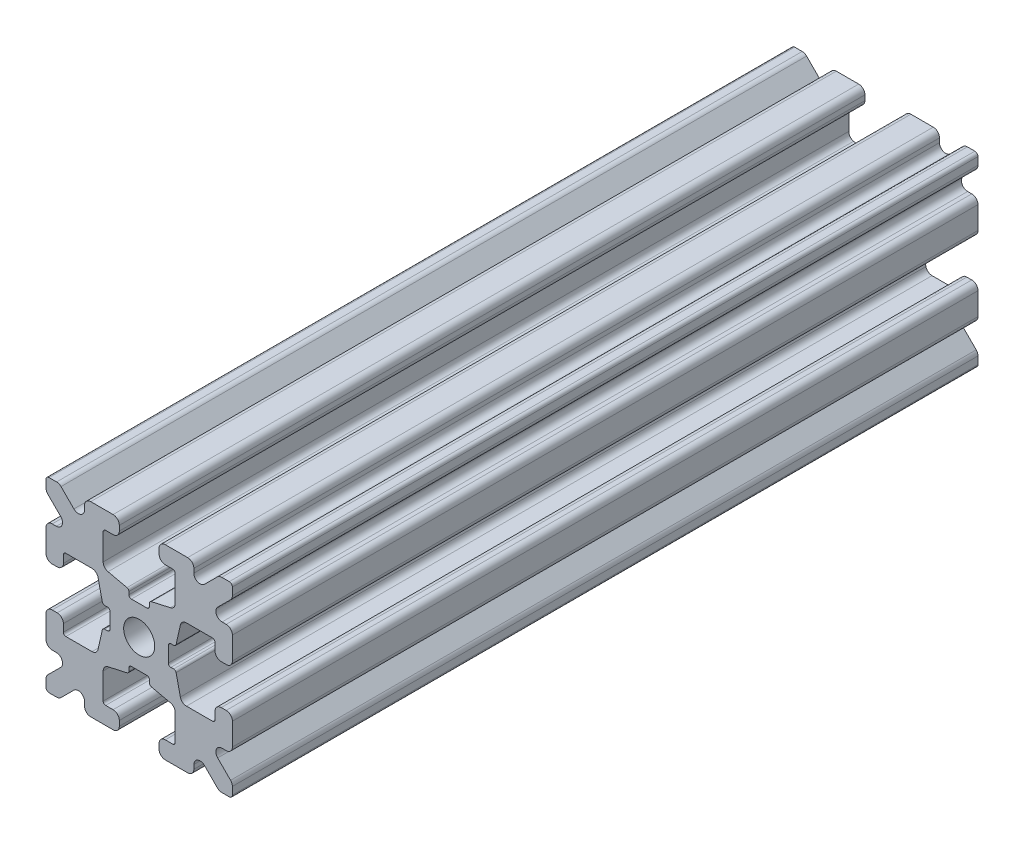
from build123d import *

# Parameters (mm, degrees)
PROFILE_R           = 1.25
BOSS_EXTRUDE1_DEPTH = 60


with BuildPart() as part:
    # Profile → Boss-Extrude1 (new body)
    with BuildSketch(Plane.XY):
        with BuildLine():
            Line((0.6255, -2.3470646), (-0.6255, -2.3470646))
            ThreePointArc((-0.6255, -2.3470646), (-0.766921356, -2.405643244), (-0.8255, -2.5470646))
            Line((-0.8255, -2.5470646), (-0.8255, -2.774891226))
            ThreePointArc((-0.8255, -2.774891226), (-0.869377519, -2.89989431), (-0.981757709, -2.970049142))
            Line((-0.981757709, -2.970049142), (-2.509355729, -3.312441801))
            ThreePointArc((-2.509355729, -3.312441801), (-2.790306203, -3.487828881), (-2.9, -3.80033659))
            Line((-2.9, -3.80033659), (-2.9, -5.9))
            ThreePointArc((-2.9, -5.9), (-2.841421356, -6.041421356), (-2.7, -6.1))
            Line((-2.7, -6.1), (-2.1, -6.1))
            ThreePointArc((-2.1, -6.1), (-1.746446609, -6.246446609), (-1.6, -6.6))
            Line((-1.6, -6.6), (-1.6, -7))
            ThreePointArc((-1.6, -7), (-1.746446609, -7.353553391), (-2.1, -7.5))
            Line((-2.1, -7.5), (-3.9, -7.5))
            ThreePointArc((-3.9, -7.5), (-4.253553391, -7.353553391), (-4.4, -7))
            Line((-4.4, -7), (-4.4, -6.667766953))
            ThreePointArc((-4.4, -6.667766953), (-4.708658284, -6.205827187), (-5.253553391, -6.314213562))
            Line((-5.253553391, -6.314213562), (-6.292893219, -7.353553391))
            ThreePointArc((-6.292893219, -7.353553391), (-6.455104893, -7.461939766), (-6.646446609, -7.5))
            Line((-6.646446609, -7.5), (-7.25, -7.5))
            ThreePointArc((-7.25, -7.5), (-7.426776695, -7.426776695), (-7.5, -7.25))
            Line((-7.5, -7.25), (-7.5, -6.646446609))
            ThreePointArc((-7.5, -6.646446609), (-7.461939766, -6.455104893), (-7.353553391, -6.292893219))
            Line((-7.353553391, -6.292893219), (-6.314213562, -5.253553391))
            ThreePointArc((-6.314213562, -5.253553391), (-6.205827187, -4.708658284), (-6.667766953, -4.4))
            Line((-6.667766953, -4.4), (-7, -4.4))
            ThreePointArc((-7, -4.4), (-7.353553391, -4.253553391), (-7.5, -3.9))
            Line((-7.5, -3.9), (-7.5, -2.1))
            ThreePointArc((-7.5, -2.1), (-7.353553391, -1.746446609), (-7, -1.6))
            Line((-7, -1.6), (-6.6, -1.6))
            ThreePointArc((-6.6, -1.6), (-6.246446609, -1.746446609), (-6.1, -2.1))
            Line((-6.1, -2.1), (-6.1, -2.7))
            ThreePointArc((-6.1, -2.7), (-6.041421356, -2.841421356), (-5.9, -2.9))
            Line((-5.9, -2.9), (-3.80033659, -2.9))
            ThreePointArc((-3.80033659, -2.9), (-3.487828881, -2.790306203), (-3.312441801, -2.509355728))
            Line((-3.312441801, -2.509355728), (-2.970049142, -0.981757709))
            ThreePointArc((-2.970049142, -0.981757709), (-2.89989431, -0.869377519), (-2.774891226, -0.8255))
            Line((-2.774891226, -0.8255), (-2.5470646, -0.8255))
            ThreePointArc((-2.5470646, -0.8255), (-2.405643244, -0.766921356), (-2.3470646, -0.6255))
            Line((-2.3470646, -0.6255), (-2.3470646, 0.6255))
            ThreePointArc((-2.3470646, 0.6255), (-2.405643244, 0.766921356), (-2.5470646, 0.8255))
            Line((-2.5470646, 0.8255), (-2.774891226, 0.8255))
            ThreePointArc((-2.774891226, 0.8255), (-2.89989431, 0.869377519), (-2.970049142, 0.981757709))
            Line((-2.970049142, 0.981757709), (-3.312441801, 2.509355729))
            ThreePointArc((-3.312441801, 2.509355729), (-3.487828881, 2.790306203), (-3.80033659, 2.9))
            Line((-3.80033659, 2.9), (-5.9, 2.9))
            ThreePointArc((-5.9, 2.9), (-6.041421356, 2.841421356), (-6.1, 2.7))
            Line((-6.1, 2.7), (-6.1, 2.1))
            ThreePointArc((-6.1, 2.1), (-6.246446609, 1.746446609), (-6.6, 1.6))
            Line((-6.6, 1.6), (-7, 1.6))
            ThreePointArc((-7, 1.6), (-7.353553391, 1.746446609), (-7.5, 2.1))
            Line((-7.5, 2.1), (-7.5, 3.9))
            ThreePointArc((-7.5, 3.9), (-7.353553391, 4.253553391), (-7, 4.4))
            Line((-7, 4.4), (-6.667766953, 4.4))
            ThreePointArc((-6.667766953, 4.4), (-6.205827187, 4.708658284), (-6.314213562, 5.253553391))
            Line((-6.314213562, 5.253553391), (-7.353553391, 6.292893219))
            ThreePointArc((-7.353553391, 6.292893219), (-7.461939766, 6.455104893), (-7.5, 6.646446609))
            Line((-7.5, 6.646446609), (-7.5, 7.25))
            ThreePointArc((-7.5, 7.25), (-7.426776695, 7.426776695), (-7.25, 7.5))
            Line((-7.25, 7.5), (-6.646446609, 7.5))
            ThreePointArc((-6.646446609, 7.5), (-6.455104893, 7.461939766), (-6.292893219, 7.353553391))
            Line((-6.292893219, 7.353553391), (-5.253553391, 6.314213562))
            ThreePointArc((-5.253553391, 6.314213562), (-4.708658284, 6.205827187), (-4.4, 6.667766953))
            Line((-4.4, 6.667766953), (-4.4, 7))
            ThreePointArc((-4.4, 7), (-4.253553391, 7.353553391), (-3.9, 7.5))
            Line((-3.9, 7.5), (-2.1, 7.5))
            ThreePointArc((-2.1, 7.5), (-1.746446609, 7.353553391), (-1.6, 7))
            Line((-1.6, 7), (-1.6, 6.6))
            ThreePointArc((-1.6, 6.6), (-1.746446609, 6.246446609), (-2.1, 6.1))
            Line((-2.1, 6.1), (-2.7, 6.1))
            ThreePointArc((-2.7, 6.1), (-2.841421356, 6.041421356), (-2.9, 5.9))
            Line((-2.9, 5.9), (-2.9, 3.80033659))
            ThreePointArc((-2.9, 3.80033659), (-2.790306203, 3.487828881), (-2.509355728, 3.312441801))
            Line((-2.509355728, 3.312441801), (-0.981757709, 2.970049142))
            ThreePointArc((-0.981757709, 2.970049142), (-0.869377519, 2.89989431), (-0.8255, 2.774891226))
            Line((-0.8255, 2.774891226), (-0.8255, 2.5470646))
            ThreePointArc((-0.8255, 2.5470646), (-0.766921356, 2.405643244), (-0.6255, 2.3470646))
            Line((-0.6255, 2.3470646), (0.6255, 2.3470646))
            ThreePointArc((0.6255, 2.3470646), (0.766921356, 2.405643244), (0.8255, 2.5470646))
            Line((0.8255, 2.5470646), (0.8255, 2.774891226))
            ThreePointArc((0.8255, 2.774891226), (0.869377519, 2.89989431), (0.981757709, 2.970049142))
            Line((0.981757709, 2.970049142), (2.509355728, 3.312441801))
            ThreePointArc((2.509355728, 3.312441801), (2.790306203, 3.487828881), (2.9, 3.80033659))
            Line((2.9, 3.80033659), (2.9, 5.9))
            ThreePointArc((2.9, 5.9), (2.841421356, 6.041421356), (2.7, 6.1))
            Line((2.7, 6.1), (2.1, 6.1))
            ThreePointArc((2.1, 6.1), (1.746446609, 6.246446609), (1.6, 6.6))
            Line((1.6, 6.6), (1.6, 7))
            ThreePointArc((1.6, 7), (1.746446609, 7.353553391), (2.1, 7.5))
            Line((2.1, 7.5), (3.9, 7.5))
            ThreePointArc((3.9, 7.5), (4.253553391, 7.353553391), (4.4, 7))
            Line((4.4, 7), (4.4, 6.667766953))
            ThreePointArc((4.4, 6.667766953), (4.708658284, 6.205827187), (5.253553391, 6.314213562))
            Line((5.253553391, 6.314213562), (6.292893219, 7.353553391))
            ThreePointArc((6.292893219, 7.353553391), (6.455104893, 7.461939766), (6.646446609, 7.5))
            Line((6.646446609, 7.5), (7.25, 7.5))
            ThreePointArc((7.25, 7.5), (7.426776695, 7.426776695), (7.5, 7.25))
            Line((7.5, 7.25), (7.5, 6.646446609))
            ThreePointArc((7.5, 6.646446609), (7.461939766, 6.455104893), (7.353553391, 6.292893219))
            Line((7.353553391, 6.292893219), (6.314213562, 5.253553391))
            ThreePointArc((6.314213562, 5.253553391), (6.205827187, 4.708658284), (6.667766953, 4.4))
            Line((6.667766953, 4.4), (7, 4.4))
            ThreePointArc((7, 4.4), (7.353553391, 4.253553391), (7.5, 3.9))
            Line((7.5, 3.9), (7.5, 2.1))
            ThreePointArc((7.5, 2.1), (7.353553391, 1.746446609), (7, 1.6))
            Line((7, 1.6), (6.6, 1.6))
            ThreePointArc((6.6, 1.6), (6.246446609, 1.746446609), (6.1, 2.1))
            Line((6.1, 2.1), (6.1, 2.7))
            ThreePointArc((6.1, 2.7), (6.041421356, 2.841421356), (5.9, 2.9))
            Line((5.9, 2.9), (3.80033659, 2.9))
            ThreePointArc((3.80033659, 2.9), (3.487828881, 2.790306203), (3.312441801, 2.509355728))
            Line((3.312441801, 2.509355728), (2.970049142, 0.981757709))
            ThreePointArc((2.970049142, 0.981757709), (2.89989431, 0.869377519), (2.774891226, 0.8255))
            Line((2.774891226, 0.8255), (2.5470646, 0.8255))
            ThreePointArc((2.5470646, 0.8255), (2.405643244, 0.766921356), (2.3470646, 0.6255))
            Line((2.3470646, 0.6255), (2.3470646, -0.6255))
            ThreePointArc((2.3470646, -0.6255), (2.405643244, -0.766921356), (2.5470646, -0.8255))
            Line((2.5470646, -0.8255), (2.774891226, -0.8255))
            ThreePointArc((2.774891226, -0.8255), (2.89989431, -0.869377519), (2.970049142, -0.981757709))
            Line((2.970049142, -0.981757709), (3.312441801, -2.509355728))
            ThreePointArc((3.312441801, -2.509355728), (3.487828881, -2.790306203), (3.80033659, -2.9))
            Line((3.80033659, -2.9), (5.9, -2.9))
            ThreePointArc((5.9, -2.9), (6.041421356, -2.841421356), (6.1, -2.7))
            Line((6.1, -2.7), (6.1, -2.1))
            ThreePointArc((6.1, -2.1), (6.246446609, -1.746446609), (6.6, -1.6))
            Line((6.6, -1.6), (7, -1.6))
            ThreePointArc((7, -1.6), (7.353553391, -1.746446609), (7.5, -2.1))
            Line((7.5, -2.1), (7.5, -3.9))
            ThreePointArc((7.5, -3.9), (7.353553391, -4.253553391), (7, -4.4))
            Line((7, -4.4), (6.667766953, -4.4))
            ThreePointArc((6.667766953, -4.4), (6.205827187, -4.708658284), (6.314213562, -5.253553391))
            Line((6.314213562, -5.253553391), (7.353553391, -6.292893219))
            ThreePointArc((7.353553391, -6.292893219), (7.461939766, -6.455104893), (7.5, -6.646446609))
            Line((7.5, -6.646446609), (7.5, -7.25))
            ThreePointArc((7.5, -7.25), (7.426776695, -7.426776695), (7.25, -7.5))
            Line((7.25, -7.5), (6.646446609, -7.5))
            ThreePointArc((6.646446609, -7.5), (6.455104893, -7.461939766), (6.292893219, -7.353553391))
            Line((6.292893219, -7.353553391), (5.253553391, -6.314213562))
            ThreePointArc((5.253553391, -6.314213562), (4.708658284, -6.205827187), (4.4, -6.667766953))
            Line((4.4, -6.667766953), (4.4, -7))
            ThreePointArc((4.4, -7), (4.253553391, -7.353553391), (3.9, -7.5))
            Line((3.9, -7.5), (2.1, -7.5))
            ThreePointArc((2.1, -7.5), (1.746446609, -7.353553391), (1.6, -7))
            Line((1.6, -7), (1.6, -6.6))
            ThreePointArc((1.6, -6.6), (1.746446609, -6.246446609), (2.1, -6.1))
            Line((2.1, -6.1), (2.7, -6.1))
            ThreePointArc((2.7, -6.1), (2.841421356, -6.041421356), (2.9, -5.9))
            Line((2.9, -5.9), (2.9, -3.80033659))
            ThreePointArc((2.9, -3.80033659), (2.790306203, -3.487828881), (2.509355728, -3.312441801))
            Line((2.509355728, -3.312441801), (0.981757709, -2.970049142))
            ThreePointArc((0.981757709, -2.970049142), (0.869377519, -2.89989431), (0.8255, -2.774891226))
            Line((0.8255, -2.774891226), (0.8255, -2.5470646))
            ThreePointArc((0.8255, -2.5470646), (0.766921356, -2.405643244), (0.6255, -2.3470646))
        make_face()
        Circle(PROFILE_R, mode=Mode.SUBTRACT)
    extrude(amount=-BOSS_EXTRUDE1_DEPTH)


solid = part.part
